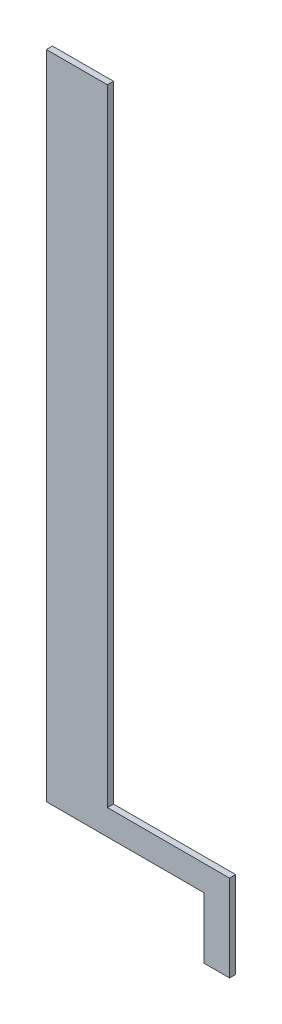
from build123d import *

# Parameters (mm, degrees)
BOSS_EXTRUDE1_DEPTH = 1.5


with BuildPart() as part:
    # Sketch1 → Boss-Extrude1 (new body, symmetric)
    with BuildSketch(Plane.XY):
        Polygon((65, -147.5), (75, -147.5), (75, -160), (75, -190), (62.5, -190), (62.5, -160), (15, -160), (-15, -160), (-15, 160), (15, 160), (15, -147.5), align=None)
    extrude(amount=BOSS_EXTRUDE1_DEPTH, both=True)


solid = part.part
